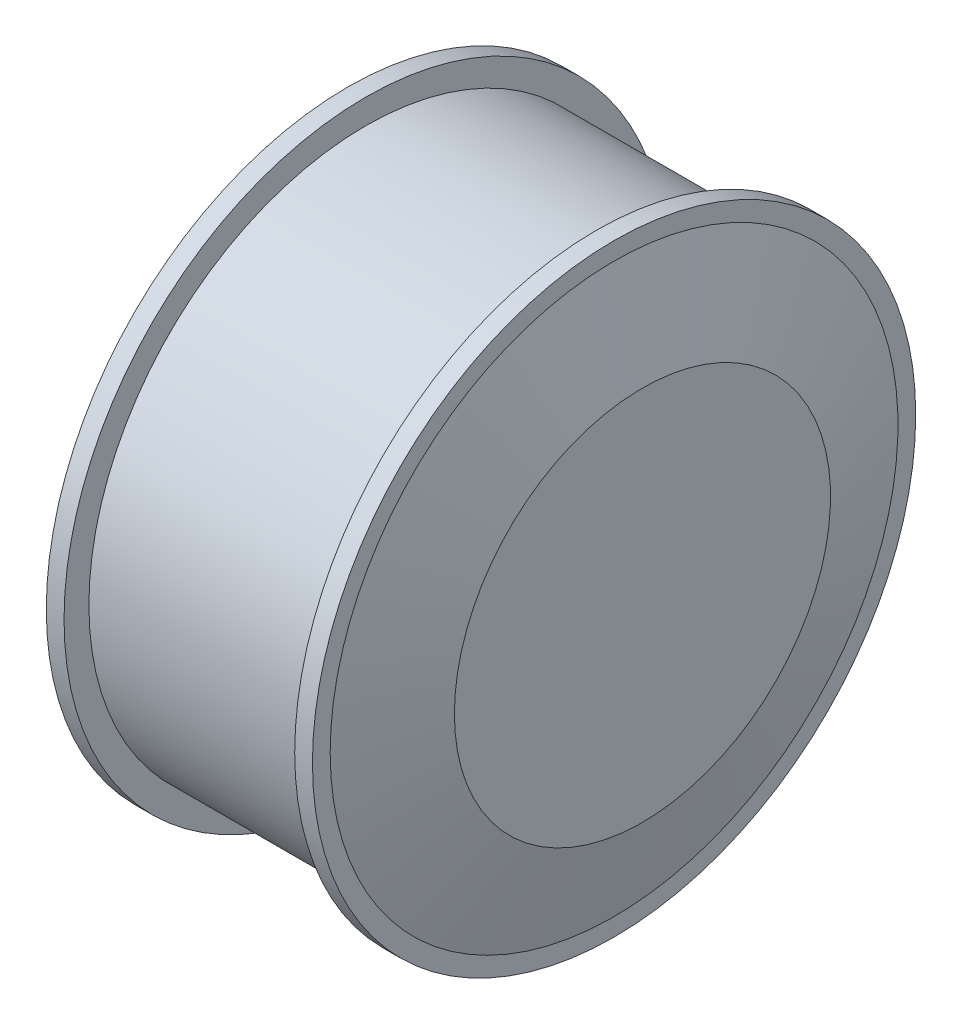
from build123d import *

# Parameters (mm, degrees)
CUT_EXTRUDE_START    = -53.5
SKETCH_2_OUTSIDE_W   = 231.472
SKETCH_2_OUTSIDE_H   = 231.472
CUT_EXTRUDE_1_DEPTH  = 35
CUT_EXTRUDE_START_2  = 53.5
SKETCH_2_2_OUTSIDE_W = 231.472
SKETCH_2_2_OUTSIDE_H = 231.472
CUT_EXTRUDE_2_DEPTH  = 35
SKETCH_3_R           = 53
CUT_EXTRUDE_3_DEPTH  = 42


with BuildPart() as part:
    # Эскиз1 → Повернуть1 (revolve)
    with BuildSketch(Plane.XY):
        Polygon((32.5, 85), (37.5, 85), (37.5, 80), (45.5, 53), (45.5, 11), (48.5, 11), (48.5, 8), (87.5, 8), (87.5, 0), (-87.5, 0), (-87.5, 8), (-48.5, 8), (-48.5, 11), (-45.5, 11), (-45.5, 53), (-37.5, 80), (-37.5, 85), (-32.5, 85), (-32.5, 78), (32.5, 78), align=None)
    revolve(axis=Axis((-1100.903674864, 0, 0), (1, 0, 0)))

    # Эскиз2 outside → Вырез-Вытянуть1 (cut, through all)
    with BuildSketch(Plane(origin=(0, 0, 0), x_dir=(0, 0, -1), z_dir=(1, 0, 0)).offset(CUT_EXTRUDE_START)):
        Rectangle(SKETCH_2_OUTSIDE_W, SKETCH_2_OUTSIDE_H)
        with BuildLine():
            Line((-6, 5.291502622), (-6, -5.291502622))
            ThreePointArc((-6, -5.291502622), (0, -8), (6, -5.291502622))
            Line((6, -5.291502622), (6, 5.291502622))
            ThreePointArc((6, 5.291502622), (0, 8), (-6, 5.291502622))
        make_face(mode=Mode.SUBTRACT)
    extrude(amount=-CUT_EXTRUDE_1_DEPTH, mode=Mode.SUBTRACT)

    # Эскиз2<2> outside → Вырез-Вытянуть2 (cut, through all)
    with BuildSketch(Plane(origin=(0, 0, 0), x_dir=(0, 0, -1), z_dir=(1, 0, 0)).offset(CUT_EXTRUDE_START_2)):
        Rectangle(SKETCH_2_2_OUTSIDE_W, SKETCH_2_2_OUTSIDE_H)
        with BuildLine():
            Line((-6, 5.291502622), (-6, -5.291502622))
            ThreePointArc((-6, -5.291502622), (0, -8), (6, -5.291502622))
            Line((6, -5.291502622), (6, 5.291502622))
            ThreePointArc((6, 5.291502622), (0, 8), (-6, 5.291502622))
        make_face(mode=Mode.SUBTRACT)
    extrude(amount=CUT_EXTRUDE_2_DEPTH, mode=Mode.SUBTRACT)

    # Эскиз3 → Вырез-Вытянуть3 (cut)
    with BuildSketch(Plane(origin=(87.5, 0, 0), x_dir=(0, 0, -1), z_dir=(1, 0, 0))):
        Circle(SKETCH_3_R)
    extrude(amount=-CUT_EXTRUDE_3_DEPTH, mode=Mode.SUBTRACT)


solid = part.part
